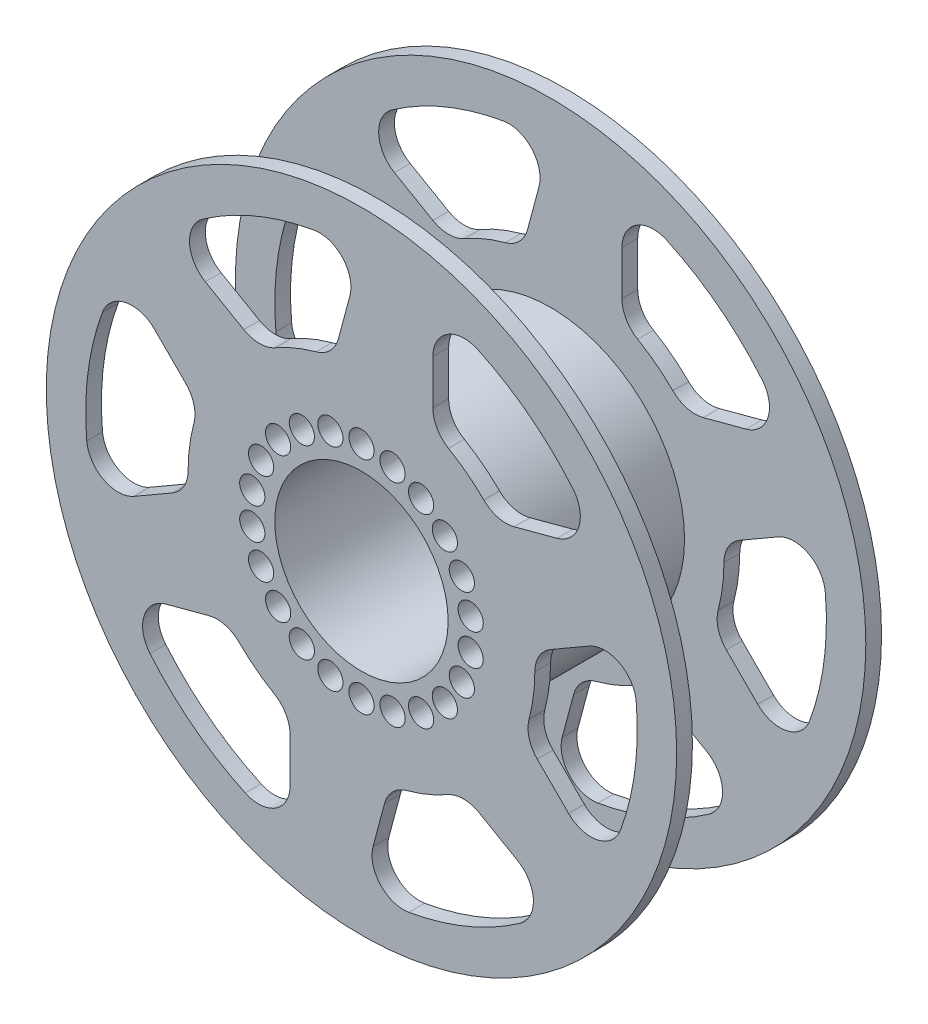
from build123d import *

# Parameters (mm, degrees)
ESBO_O1_R                    = 100
ESBO_O1_R_2                  = 27.5
RESSALTO_EXTRUS_O1_DEPTH     = 65
CORTE_EXTRUS_O1_START        = -5
ESBO_O2_R                    = 100
ESBO_O2_R_2                  = 42.5
CORTE_EXTRUS_O1_DEPTH        = 55
CORTE_EXTRUS_O2_DEPTH        = 157.3
FILETE1_R                    = 10
PADR_OCIRCULAR1_COUNT        = 6
FILETE1_OF_PADR_OCIRCULAR1_R = 10
ESBO_O4_R                    = 4
CORTE_EXTRUS_O3_DEPTH        = 157.3
PADR_OCIRCULAR2_COUNT        = 22


with BuildPart() as part:
    # Esboço1 → Ressalto-extrusão1 (new body)
    with BuildSketch(Plane.XY):
        Circle(ESBO_O1_R)
        Circle(ESBO_O1_R_2, mode=Mode.SUBTRACT)
    extrude(amount=RESSALTO_EXTRUS_O1_DEPTH)

    # Esboço2 → Corte-extrusão1 (cut)
    with BuildSketch(Plane.XY.offset(65).offset(CORTE_EXTRUS_O1_START)):
        Circle(ESBO_O2_R)
        Circle(ESBO_O2_R_2, mode=Mode.SUBTRACT)
    extrude(amount=-CORTE_EXTRUS_O1_DEPTH, mode=Mode.SUBTRACT)

    # Esboço3 → Corte-extrusão2 (cut)
    with BuildSketch(Plane.XY.offset(65)):
        with BuildLine():
            ThreePointArc((0, 87.5), (-33.484800332, 80.839459095), (-61.871843354, 61.871843354))
            Line((-61.871843354, 61.871843354), (-32.082845763, 44.673157576))
            ThreePointArc((-32.082845763, 44.673157576), (-21.04758878, 50.813374288), (-8.90269486, 54.274690457))
            Line((-8.90269486, 54.274690457), (0, 87.5))
        make_face()
    corte_extrus_o2 = extrude(amount=-CORTE_EXTRUS_O2_DEPTH, mode=Mode.SUBTRACT)

    # Filete1
    filete1_edges = [part.edges().sort_by_distance(p)[0] for p in [
        (0, 87.5, 2.5),
        (0, 87.5, 62.5),
        (-8.90269486, 54.274690457, 2.5),
        (-8.90269486, 54.274690457, 62.5),
        (-32.082845763, 44.673157576, 2.5),
        (-32.082845763, 44.673157576, 62.5),
        (-61.871843354, 61.871843354, 2.5),
        (-61.871843354, 61.871843354, 62.5),
    ]]
    fillet(filete1_edges, radius=FILETE1_R)

    # PadrãoCircular1: Corte-extrusão2 ×6 about axis
    padr_ocircular1_axis = Axis((0, 0, 0), (0, 0, 1))
    for i in range(1, PADR_OCIRCULAR1_COUNT):
        add(corte_extrus_o2.rotate(padr_ocircular1_axis, i * 360 / PADR_OCIRCULAR1_COUNT), mode=Mode.SUBTRACT)

    # Filete1 of PadrãoCircular1
    filete1_of_padr_ocircular1_edges = [part.edges().sort_by_distance(p)[0] for p in [
        (-75.777222831, 43.75, 2.5),
        (-75.777222831, 43.75, 62.5),
        (-51.454608149, 19.427385317, 2.5),
        (-51.454608149, 19.427385317, 62.5),
        (-54.729512209, -5.447980668, 2.5),
        (-54.729512209, -5.447980668, 62.5),
        (-84.5185098, -22.646666446, 2.5),
        (-84.5185098, -22.646666446, 62.5),
        (-75.777222831, -43.75, 2.5),
        (-75.777222831, -43.75, 62.5),
        (-42.551913288, -34.84730514, 2.5),
        (-42.551913288, -34.84730514, 62.5),
        (-22.646666446, -50.121138244, 2.5),
        (-22.646666446, -50.121138244, 62.5),
        (-22.646666446, -84.5185098, 2.5),
        (-22.646666446, -84.5185098, 62.5),
        (0, -87.5, 2.5),
        (0, -87.5, 62.5),
        (8.90269486, -54.274690457, 2.5),
        (8.90269486, -54.274690457, 62.5),
        (32.082845763, -44.673157576, 2.5),
        (32.082845763, -44.673157576, 62.5),
        (61.871843354, -61.871843354, 2.5),
        (61.871843354, -61.871843354, 62.5),
        (75.777222831, -43.75, 2.5),
        (75.777222831, -43.75, 62.5),
        (51.454608149, -19.427385317, 2.5),
        (51.454608149, -19.427385317, 62.5),
        (54.729512209, 5.447980668, 2.5),
        (54.729512209, 5.447980668, 62.5),
        (84.5185098, 22.646666446, 2.5),
        (84.5185098, 22.646666446, 62.5),
        (75.777222831, 43.75, 2.5),
        (75.777222831, 43.75, 62.5),
        (42.551913288, 34.84730514, 2.5),
        (42.551913288, 34.84730514, 62.5),
        (22.646666446, 50.121138244, 2.5),
        (22.646666446, 50.121138244, 62.5),
        (22.646666446, 84.5185098, 2.5),
        (22.646666446, 84.5185098, 62.5),
    ]]
    fillet(filete1_of_padr_ocircular1_edges, radius=FILETE1_OF_PADR_OCIRCULAR1_R)

    # Esboço4 → Corte-extrusão3 (cut)
    with BuildSketch(Plane.XY.offset(65)):
        with Locations((0, 35)):
            Circle(ESBO_O4_R)
    corte_extrus_o3 = extrude(amount=-CORTE_EXTRUS_O3_DEPTH, mode=Mode.SUBTRACT)

    # PadrãoCircular2: Corte-extrusão3 ×22 about axis
    padr_ocircular2_axis = Axis((0, 0, 0), (0, 0, 1))
    for i in range(1, PADR_OCIRCULAR2_COUNT):
        add(corte_extrus_o3.rotate(padr_ocircular2_axis, i * 360 / PADR_OCIRCULAR2_COUNT), mode=Mode.SUBTRACT)


solid = part.part
